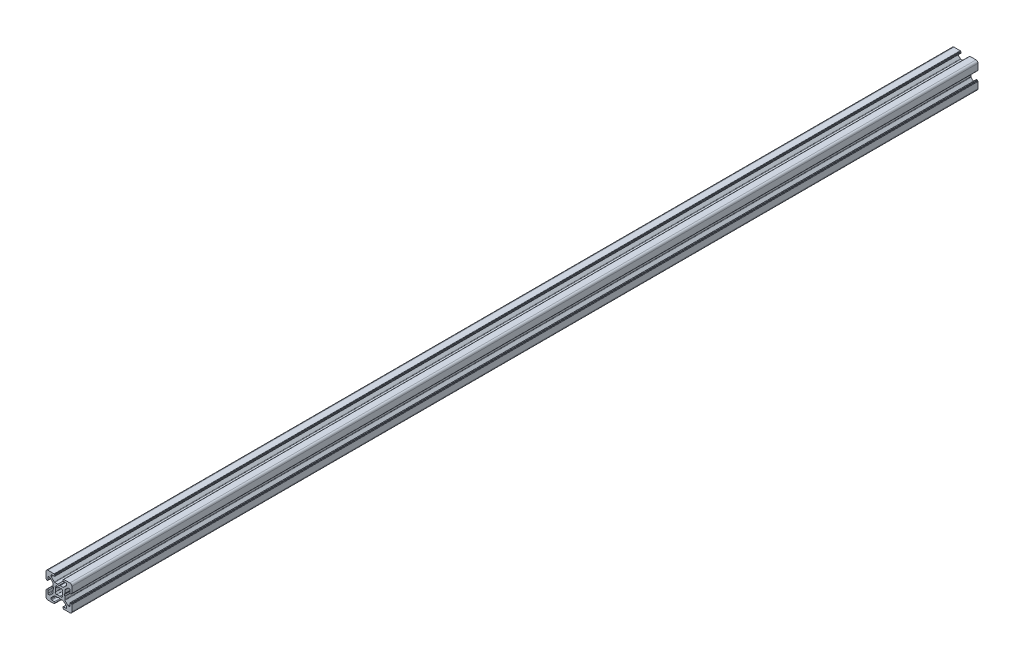
from build123d import *

# Parameters (mm, degrees)
SALIENTE_EXTRUIR_DEPTH = 700


with BuildPart() as part:
    # Croquis → Saliente_Extruir (new body)
    with BuildSketch(Plane.XY):
        with BuildLine():
            Line((6.249999773, 6.250000395), (1.5, 6.250000395))
            ThreePointArc((1.5, 6.250000395), (0.439339828, 5.810660567), (0, 4.750000395))
            Line((0, 4.750000395), (0, 0))
            ThreePointArc((0, 0), (0.058578644, -0.141421356), (0.2, -0.2))
            Line((0.2, -0.2), (0.300000268, -0.2))
            ThreePointArc((0.300000268, -0.2), (0.441421624, -0.258578644), (0.500000268, -0.4))
            Line((0.500000268, -0.4), (0.500000268, -0.549999605))
            ThreePointArc((0.500000268, -0.549999605), (0.558578912, -0.691420961), (0.700000268, -0.749999605))
            Line((0.700000268, -0.749999605), (1.000000268, -0.749999605))
            ThreePointArc((1.000000268, -0.749999605), (1.353553659, -0.603552995), (1.500000268, -0.249999605))
            Line((1.500000268, -0.249999605), (1.500000268, 1.75))
            ThreePointArc((1.500000268, 1.75), (1.646446877, 2.103553391), (2.000000268, 2.25))
            Line((2.000000268, 2.25), (2.732233315, 2.25))
            ThreePointArc((2.732233315, 2.25), (2.923575031, 2.211939766), (3.085786706, 2.103553391))
            Line((3.085786706, 2.103553391), (5.353553602, -0.164213506))
            ThreePointArc((5.353553602, -0.164213506), (5.461939977, -0.32642518), (5.500000211, -0.517766896))
            Line((5.500000211, -0.517766896), (5.500000211, -2.796410303))
            ThreePointArc((5.500000211, -2.796410303), (5.506815047, -2.848174114), (5.526795133, -2.896410307))
            Line((5.526795133, -2.896410307), (5.961880159, -3.649999636))
            ThreePointArc((5.961880159, -3.649999636), (5.988675071, -3.749999605), (5.961880159, -3.849999574))
            Line((5.961880159, -3.849999574), (5.526795133, -4.603588902))
            ThreePointArc((5.526795133, -4.603588902), (5.506815046, -4.651825095), (5.500000211, -4.703588906))
            Line((5.500000211, -4.703588906), (5.500000211, -6.982232313))
            ThreePointArc((5.500000211, -6.982232313), (5.461939977, -7.173574029), (5.353553602, -7.335785704))
            Line((5.353553602, -7.335785704), (3.085786706, -9.6035526))
            ThreePointArc((3.085786706, -9.6035526), (2.923575031, -9.711938976), (2.732233315, -9.749999209))
            Line((2.732233315, -9.749999209), (2.000000268, -9.749999209))
            ThreePointArc((2.000000268, -9.749999209), (1.646446877, -9.6035526), (1.500000268, -9.249999209))
            Line((1.500000268, -9.249999209), (1.500000268, -7.249999605))
            ThreePointArc((1.500000268, -7.249999605), (1.353553659, -6.896446214), (1.000000268, -6.749999605))
            Line((1.000000268, -6.749999605), (0.700000268, -6.749999605))
            ThreePointArc((0.700000268, -6.749999605), (0.558578912, -6.808578248), (0.500000268, -6.949999605))
            Line((0.500000268, -6.949999605), (0.500000268, -7.099999209))
            ThreePointArc((0.500000268, -7.099999209), (0.441421624, -7.241420566), (0.300000268, -7.299999209))
            Line((0.300000268, -7.299999209), (0.2, -7.299999209))
            ThreePointArc((0.2, -7.299999209), (0.058578644, -7.358577853), (0, -7.499999209))
            Line((0, -7.499999209), (0, -12.249999605))
            ThreePointArc((0, -12.249999605), (0.439339828, -13.310659776), (1.5, -13.749999605))
            Line((1.5, -13.749999605), (6.249999772, -13.749999605))
            ThreePointArc((6.249999772, -13.749999605), (6.391421129, -13.691420961), (6.449999772, -13.549999605))
            Line((6.449999772, -13.549999605), (6.449999772, -13.449999605))
            ThreePointArc((6.449999772, -13.449999605), (6.508578416, -13.308578248), (6.649999772, -13.249999605))
            Line((6.649999772, -13.249999605), (6.8, -13.249999605))
            ThreePointArc((6.8, -13.249999605), (6.941421356, -13.191420961), (7, -13.049999605))
            Line((7, -13.049999605), (7, -12.749999278))
            ThreePointArc((7, -12.749999278), (6.853553391, -12.396445888), (6.5, -12.249999278))
            Line((6.5, -12.249999278), (4.499999314, -12.249999278))
            ThreePointArc((4.499999314, -12.249999278), (4.146445923, -12.103552669), (3.999999314, -11.749999278))
            Line((3.999999314, -11.749999278), (3.999999314, -11.017766231))
            ThreePointArc((3.999999314, -11.017766231), (4.038059552, -10.826424504), (4.146445941, -10.664212823))
            Line((4.146445941, -10.664212823), (6.414212788, -8.396446197))
            ThreePointArc((6.414212788, -8.396446197), (6.576424456, -8.288059834), (6.767766161, -8.249999605))
            Line((6.767766161, -8.249999605), (9.046409688, -8.249999605))
            ThreePointArc((9.046409688, -8.249999605), (9.098173495, -8.243184771), (9.146409684, -8.223204688))
            Line((9.146409684, -8.223204688), (9.899999955, -7.788119166))
            ThreePointArc((9.899999955, -7.788119166), (10, -7.761324236), (10.100000045, -7.788119166))
            Line((10.100000045, -7.788119166), (10.853590316, -8.223204688))
            ThreePointArc((10.853590316, -8.223204688), (10.901826505, -8.243184771), (10.953590312, -8.249999605))
            Line((10.953590312, -8.249999605), (13.232233839, -8.249999605))
            ThreePointArc((13.232233839, -8.249999605), (13.423575544, -8.288059834), (13.585787212, -8.396446197))
            Line((13.585787212, -8.396446197), (15.853554059, -10.664212823))
            ThreePointArc((15.853554059, -10.664212823), (15.961940448, -10.826424504), (16.000000686, -11.017766231))
            Line((16.000000686, -11.017766231), (16.000000686, -11.749999278))
            ThreePointArc((16.000000686, -11.749999278), (15.853554077, -12.103552669), (15.500000686, -12.249999278))
            Line((15.500000686, -12.249999278), (13.5, -12.249999278))
            ThreePointArc((13.5, -12.249999278), (13.146446609, -12.396445888), (13, -12.749999278))
            Line((13, -12.749999278), (13, -13.049999605))
            ThreePointArc((13, -13.049999605), (13.058578644, -13.191420961), (13.2, -13.249999605))
            Line((13.2, -13.249999605), (13.350000227, -13.249999605))
            ThreePointArc((13.350000227, -13.249999605), (13.491421584, -13.308578248), (13.550000227, -13.449999605))
            Line((13.550000227, -13.449999605), (13.550000227, -13.549999605))
            ThreePointArc((13.550000227, -13.549999605), (13.608578871, -13.691420961), (13.750000227, -13.749999605))
            Line((13.750000227, -13.749999605), (18.5, -13.749999605))
            ThreePointArc((18.5, -13.749999605), (19.560660172, -13.310659776), (20, -12.249999605))
            Line((20, -12.249999605), (20, -7.499999209))
            ThreePointArc((20, -7.499999209), (19.941421356, -7.358577853), (19.8, -7.299999209))
            Line((19.8, -7.299999209), (19.699999732, -7.299999209))
            ThreePointArc((19.699999732, -7.299999209), (19.558578376, -7.241420566), (19.499999732, -7.099999209))
            Line((19.499999732, -7.099999209), (19.499999732, -6.949999605))
            ThreePointArc((19.499999732, -6.949999605), (19.441421088, -6.808578248), (19.299999732, -6.749999605))
            Line((19.299999732, -6.749999605), (18.999999732, -6.749999605))
            ThreePointArc((18.999999732, -6.749999605), (18.646446341, -6.896446214), (18.499999732, -7.249999605))
            Line((18.499999732, -7.249999605), (18.499999732, -9.249999209))
            ThreePointArc((18.499999732, -9.249999209), (18.353553123, -9.6035526), (17.999999732, -9.749999209))
            Line((17.999999732, -9.749999209), (17.267766685, -9.749999209))
            ThreePointArc((17.267766685, -9.749999209), (17.076424969, -9.711938976), (16.914213294, -9.6035526))
            Line((16.914213294, -9.6035526), (14.646446398, -7.335785704))
            ThreePointArc((14.646446398, -7.335785704), (14.538060023, -7.173574029), (14.499999789, -6.982232313))
            Line((14.499999789, -6.982232313), (14.499999789, -4.703588906))
            ThreePointArc((14.499999789, -4.703588906), (14.493184953, -4.651825095), (14.473204867, -4.603588902))
            Line((14.473204867, -4.603588902), (14.038119841, -3.849999574))
            ThreePointArc((14.038119841, -3.849999574), (14.011324929, -3.749999605), (14.038119841, -3.649999636))
            Line((14.038119841, -3.649999636), (14.473204867, -2.896410307))
            ThreePointArc((14.473204867, -2.896410307), (14.493184953, -2.848174114), (14.499999789, -2.796410303))
            Line((14.499999789, -2.796410303), (14.499999789, -0.517766896))
            ThreePointArc((14.499999789, -0.517766896), (14.538060023, -0.32642518), (14.646446398, -0.164213506))
            Line((14.646446398, -0.164213506), (16.914213294, 2.103553391))
            ThreePointArc((16.914213294, 2.103553391), (17.076424969, 2.211939766), (17.267766685, 2.25))
            Line((17.267766685, 2.25), (17.999999732, 2.25))
            ThreePointArc((17.999999732, 2.25), (18.353553123, 2.103553391), (18.499999732, 1.75))
            Line((18.499999732, 1.75), (18.499999732, -0.249999605))
            ThreePointArc((18.499999732, -0.249999605), (18.646446341, -0.603552995), (18.999999732, -0.749999605))
            Line((18.999999732, -0.749999605), (19.299999732, -0.749999605))
            ThreePointArc((19.299999732, -0.749999605), (19.441421088, -0.691420961), (19.499999732, -0.549999605))
            Line((19.499999732, -0.549999605), (19.499999732, -0.4))
            ThreePointArc((19.499999732, -0.4), (19.558578376, -0.258578644), (19.699999732, -0.2))
            Line((19.699999732, -0.2), (19.8, -0.2))
            ThreePointArc((19.8, -0.2), (19.941421356, -0.141421356), (20, 0))
            Line((20, 0), (20, 4.750000395))
            ThreePointArc((20, 4.750000395), (19.560660172, 5.810660567), (18.5, 6.250000395))
            Line((18.5, 6.250000395), (13.750000228, 6.250000395))
            ThreePointArc((13.750000228, 6.250000395), (13.608578871, 6.191421752), (13.550000228, 6.050000395))
            Line((13.550000228, 6.050000395), (13.550000228, 5.950000395))
            ThreePointArc((13.550000228, 5.950000395), (13.491421584, 5.808579039), (13.350000228, 5.750000395))
            Line((13.350000228, 5.750000395), (13.2, 5.750000395))
            ThreePointArc((13.2, 5.750000395), (13.058578644, 5.691421752), (13, 5.550000395))
            Line((13, 5.550000395), (13, 5.250000069))
            ThreePointArc((13, 5.250000069), (13.146446609, 4.896446678), (13.5, 4.750000069))
            Line((13.5, 4.750000069), (15.500000686, 4.750000069))
            ThreePointArc((15.500000686, 4.750000069), (15.853554077, 4.603553459), (16.000000686, 4.250000069))
            Line((16.000000686, 4.250000069), (16.000000686, 3.517767022))
            ThreePointArc((16.000000686, 3.517767022), (15.961940448, 3.326425294), (15.853554059, 3.164213614))
            Line((15.853554059, 3.164213614), (13.585787212, 0.896446988))
            ThreePointArc((13.585787212, 0.896446988), (13.423575544, 0.788060624), (13.232233839, 0.750000395))
            Line((13.232233839, 0.750000395), (10.953590312, 0.750000395))
            ThreePointArc((10.953590312, 0.750000395), (10.901826505, 0.743185561), (10.853590316, 0.723205479))
            Line((10.853590316, 0.723205479), (10.100000045, 0.288119957))
            ThreePointArc((10.100000045, 0.288119957), (10, 0.261325027), (9.899999955, 0.288119957))
            Line((9.899999955, 0.288119957), (9.146409684, 0.723205479))
            ThreePointArc((9.146409684, 0.723205479), (9.098173495, 0.743185561), (9.046409688, 0.750000395))
            Line((9.046409688, 0.750000395), (6.767766161, 0.750000395))
            ThreePointArc((6.767766161, 0.750000395), (6.576424456, 0.788060624), (6.414212788, 0.896446988))
            Line((6.414212788, 0.896446988), (4.146445941, 3.164213614))
            ThreePointArc((4.146445941, 3.164213614), (4.038059552, 3.326425294), (3.999999314, 3.517767022))
            Line((3.999999314, 3.517767022), (3.999999314, 4.250000069))
            ThreePointArc((3.999999314, 4.250000069), (4.146445923, 4.603553459), (4.499999314, 4.750000069))
            Line((4.499999314, 4.750000069), (6.5, 4.750000069))
            ThreePointArc((6.5, 4.750000069), (6.853553391, 4.896446678), (7, 5.250000069))
            Line((7, 5.250000069), (7, 5.550000395))
            ThreePointArc((7, 5.550000395), (6.941421356, 5.691421752), (6.8, 5.750000395))
            Line((6.8, 5.750000395), (6.649999772, 5.750000395))
            ThreePointArc((6.649999772, 5.750000395), (6.508578416, 5.808579039), (6.449999772, 5.950000395))
            Line((6.449999772, 5.950000395), (6.449999772, 6.050000395))
            ThreePointArc((6.449999772, 6.050000395), (6.391421129, 6.191421752), (6.249999773, 6.250000395))
        make_face()
        with BuildLine():
            Line((7.007825047, -1.840068643), (7.554704576, -2.491814288))
            ThreePointArc((7.554704576, -2.491814288), (7.25, -3.749999605), (7.554704576, -5.008184922))
            Line((7.554704576, -5.008184922), (7.007825046, -5.659930566))
            ThreePointArc((7.007825046, -5.659930566), (7.488262739, -6.25841009), (8.08610498, -6.739640567))
            Line((8.08610498, -6.739640567), (8.741814564, -6.195294967))
            ThreePointArc((8.741814564, -6.195294967), (10, -6.499999605), (11.258185436, -6.195294967))
            Line((11.258185436, -6.195294967), (11.913895019, -6.739640567))
            ThreePointArc((11.913895019, -6.739640567), (12.511737261, -6.25841009), (12.992174953, -5.659930566))
            Line((12.992174953, -5.659930566), (12.445295423, -5.008184922))
            ThreePointArc((12.445295423, -5.008184922), (12.75, -3.749999605), (12.445295423, -2.491814288))
            Line((12.445295423, -2.491814288), (12.992174953, -1.840068643))
            ThreePointArc((12.992174953, -1.840068643), (12.511737261, -1.241589119), (11.913895019, -0.760358642))
            Line((11.913895019, -0.760358642), (11.258185436, -1.304704243))
            ThreePointArc((11.258185436, -1.304704243), (10, -0.999999605), (8.741814564, -1.304704243))
            Line((8.741814564, -1.304704243), (8.08610498, -0.760358642))
            ThreePointArc((8.08610498, -0.760358642), (7.488262739, -1.241589119), (7.007825047, -1.840068643))
        make_face(mode=Mode.SUBTRACT)
    extrude(amount=SALIENTE_EXTRUIR_DEPTH)


solid = part.part
